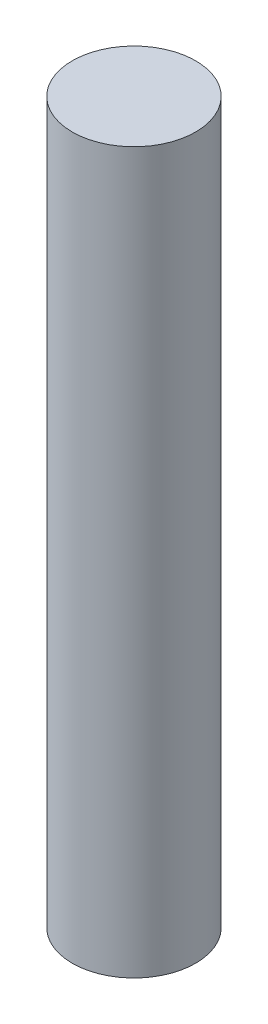
from build123d import *

# Parameters (mm, degrees)
SKETCH1_R           = 3
BOSS_EXTRUDE1_DEPTH = 35


with BuildPart() as part:
    # Sketch1 → Boss-Extrude1 (new body)
    with BuildSketch(Plane(origin=(0, 0, 0), x_dir=(1, 0, 0), z_dir=(0, 1, 0))):
        with Locations(Location((0, 0, 0), (0, 0, 270))):  # turned: the seam where the file's is
            Circle(SKETCH1_R)
    extrude(amount=BOSS_EXTRUDE1_DEPTH)


solid = part.part
